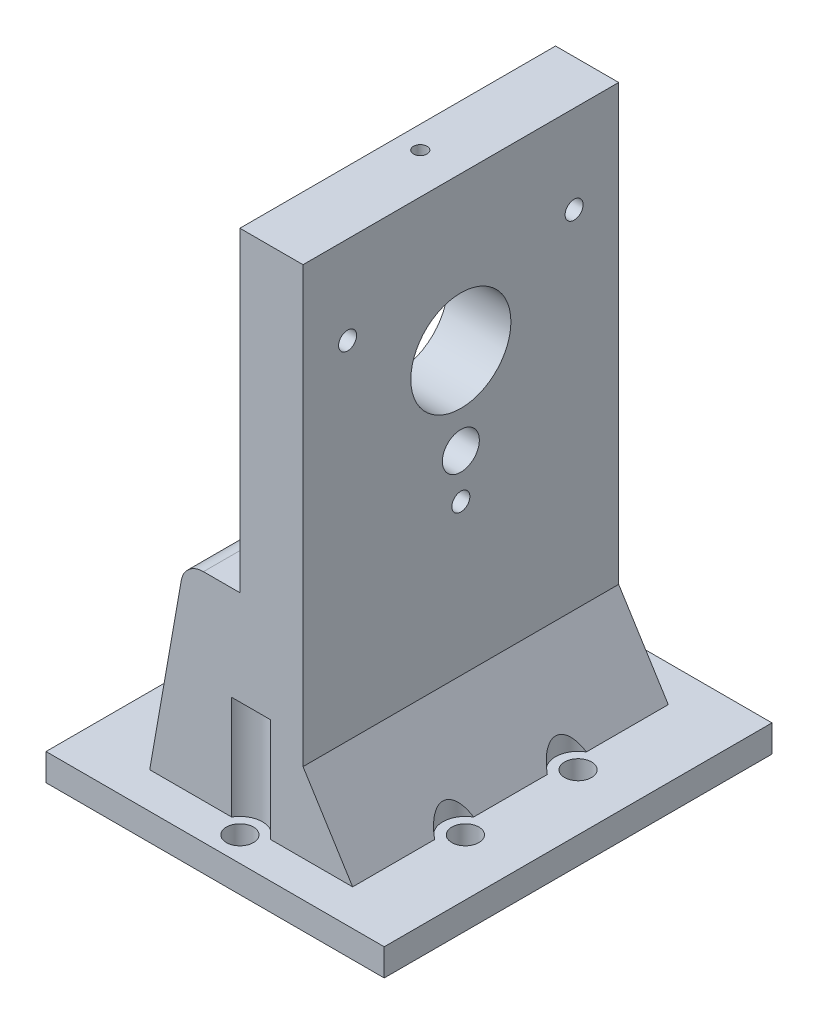
from build123d import *

# Parameters (mm, degrees)
SKETCH_1_W               = 35
SKETCH_1_H               = 70
EXTRUDE_1_DEPTH          = 6
SKETCH_1_W_2             = 26
EXTRUDE_1_2_DEPTH        = 6
SKETCH_1_3_W             = 14
SKETCH_1_3_H             = 70
EXTRUDE_2_DEPTH          = 120
EXTRUDE_4_DEPTH          = 70
EXTRUDE_7_DEPTH          = 70
SKETCH_7_R               = 3
CUT_EXTRUDE_4_DEPTH      = 121
SKETCH_8_R               = 5
CUT_EXTRUDE_5_DEPTH      = 115
SKETCH_3_R               = 11.1
SKETCH_3_R_2             = 4.1
SKETCH_3_R_3             = 2
CUT_EXTRUDE_8_DEPTH      = 36
CUT_EXTRUDE_8_DEPTH_BACK = 41
SKETCH_10_W              = 75
SKETCH_10_H              = 24
EXTRUDE_8_DEPTH          = 6
CUT_EXTRUDE_START        = -6
SKETCH_11_R              = 3
CUT_EXTRUDE_9_DEPTH      = 29
SKETCH_12_W              = 56.46589335
SKETCH_12_H              = 70
CUT_EXTRUDE_10_DEPTH     = 70
FILLET_1_R               = 5
SKETCH_13_R              = 5
CUT_EXTRUDE_11_DEPTH     = 23
SKETCH_14_W              = 75
SKETCH_14_H              = 16
CUT_EXTRUDE_12_DEPTH     = 10
SKETCH_15_R              = 1.5
CUT_EXTRUDE_13_DEPTH     = 6.25
SKETCH_16_R              = 1.5
CUT_EXTRUDE_14_DEPTH     = 6


with BuildPart() as part:
    # 草图1 → 凸台-拉伸1 (new body)
    with BuildSketch(Plane(origin=(0, 0, 0), x_dir=(1, 0, 0), z_dir=(0, 1, 0))):
        with Locations((17.5, -35)):
            Rectangle(SKETCH_1_W, SKETCH_1_H)
    extrude(amount=EXTRUDE_1_DEPTH)



with BuildPart() as body_2:
    # 草图1 → Extrude 1 2 (new body)
    with BuildSketch(Plane(origin=(0, 0, 0), x_dir=(1, 0, 0), z_dir=(0, 1, 0))):
        with Locations((62, -35)):
            Rectangle(SKETCH_1_W_2, SKETCH_1_H)
    extrude(amount=EXTRUDE_1_2_DEPTH)


with BuildPart() as part_1:
    add(part.part)

    add(body_2.part)  # 凸台-拉伸2 merges body 2
    # 草图1<3> → 凸台-拉伸2 (add)
    with BuildSketch(Plane(origin=(0, 0, 0), x_dir=(1, 0, 0), z_dir=(0, 1, 0))):
        with Locations((42, -35)):
            Rectangle(SKETCH_1_3_W, SKETCH_1_3_H)
    extrude(amount=EXTRUDE_2_DEPTH)

    # 草图4 → 凸台-拉伸4 (add, through all)
    with BuildSketch(Plane(origin=(0, 0, 0), x_dir=(-1, 0, 0), z_dir=(0, 0, -1))):
        Polygon((-35, 6), (-15, 6), (-35, 38), align=None)
        Polygon((-60, 6), (-40, 38), (-40, 6), align=None)
    extrude(amount=-EXTRUDE_4_DEPTH)

    # 草图9 → 凸台-拉伸7 (add, through all)
    with BuildSketch(Plane(origin=(0, 0, 0), x_dir=(-1, 0, 0), z_dir=(0, 0, -1))):
        Polygon((-35, 120), (-15, 6), (-35, 0), align=None)
    extrude(amount=-EXTRUDE_7_DEPTH)

    # 草图7 → 切除-拉伸4 (cut, through all)
    with BuildSketch(Plane.XZ):
        with Locations((62.5, 47.5)):
            Circle(SKETCH_7_R)
        with Locations((62.5, 22.5)):
            Circle(SKETCH_7_R)
        with Locations((12.5, 22.5)):
            Circle(SKETCH_7_R)
        with Locations((12.5, 47.5)):
            Circle(SKETCH_7_R)
    extrude(amount=-CUT_EXTRUDE_4_DEPTH, mode=Mode.SUBTRACT)

    # 草图8 → 切除-拉伸5 (cut)
    with BuildSketch(Plane(origin=(0, 6, 0), x_dir=(1, 0, 0), z_dir=(0, 1, 0))):
        with Locations((12.5, -47.5)):
            Circle(SKETCH_8_R)
        with Locations((12.5, -22.5)):
            Circle(SKETCH_8_R)
        with Locations((62.5, -47.5)):
            Circle(SKETCH_8_R)
        with Locations((62.5, -22.5)):
            Circle(SKETCH_8_R)
    extrude(amount=CUT_EXTRUDE_5_DEPTH, mode=Mode.SUBTRACT)

    # 草图3 → 切除-拉伸8 (cut, two sides)
    with BuildSketch(Plane.ZY.offset(-35)) as cut_extrude_8_sk:
        with Locations((35, 86)):
            Circle(SKETCH_3_R)
        with Locations((35, 66.75)):
            Circle(SKETCH_3_R_2)
        with Locations((35, 57)):
            Circle(SKETCH_3_R_3)
        with Locations((9.88526329, 100.5)):
            Circle(SKETCH_3_R_3)
        with Locations((60.11473671, 100.5)):
            Circle(SKETCH_3_R_3)
    extrude(amount=CUT_EXTRUDE_8_DEPTH, mode=Mode.SUBTRACT)
    extrude(cut_extrude_8_sk.sketch, amount=-CUT_EXTRUDE_8_DEPTH_BACK, mode=Mode.SUBTRACT)

    # 草图10 → 凸台-拉伸8 (add)
    with BuildSketch(Plane.XZ):
        with Locations((37.5, 82)):
            Rectangle(SKETCH_10_W, SKETCH_10_H)
    extrude_8 = extrude(amount=-EXTRUDE_8_DEPTH)

    # 草图11 → 切除-拉伸9 (cut)
    with BuildSketch(Plane(origin=(0, 6, 0), x_dir=(1, 0, 0), z_dir=(0, 1, 0)).offset(CUT_EXTRUDE_START)):
        with Locations((37.5, -72.5)):
            Circle(SKETCH_11_R)
    cut_extrude_9 = extrude(amount=CUT_EXTRUDE_9_DEPTH, mode=Mode.SUBTRACT)

    # 镜向1: 凸台-拉伸8, 切除-拉伸9 across plane
    add(extrude_8.mirror(Plane.XY.offset(35)))
    add(cut_extrude_9.mirror(Plane.XY.offset(35)), mode=Mode.SUBTRACT)

    # 草图12 → 切除-拉伸10 (cut)
    with BuildSketch(Plane(origin=(0, 120, 0), x_dir=(1, 0, 0), z_dir=(0, 1, 0))):
        with Locations((6.767053325, -35)):
            Rectangle(SKETCH_12_W, SKETCH_12_H)
    extrude(amount=-CUT_EXTRUDE_10_DEPTH, mode=Mode.SUBTRACT)

    # 圆角1
    fillet_1_edges = [part_1.edges().sort_by_distance(p)[0] for p in [
        (22.719298246, 50, 35),
    ]]
    fillet(fillet_1_edges, radius=FILLET_1_R)

    # 草图13 → 切除-拉伸11 (cut)
    with BuildSketch(Plane(origin=(0, 6, 0), x_dir=(1, 0, 0), z_dir=(0, 1, 0))):
        with Locations((37.5, -72.5)):
            Circle(SKETCH_13_R)
        with Locations((37.5, 2.5)):
            Circle(SKETCH_13_R)
    extrude(amount=CUT_EXTRUDE_11_DEPTH, mode=Mode.SUBTRACT)

    # 草图14 → 切除-拉伸12 (cut)
    with BuildSketch(Plane(origin=(0, 6, 0), x_dir=(1, 0, 0), z_dir=(0, 1, 0))):
        with Locations((37.5, 16)):
            Rectangle(SKETCH_14_W, SKETCH_14_H)
        with Locations((37.5, -86)):
            Rectangle(SKETCH_14_W, SKETCH_14_H)
    extrude(amount=-CUT_EXTRUDE_12_DEPTH, mode=Mode.SUBTRACT)

    # 草图15 → 切除-拉伸13 (cut)
    with BuildSketch(Plane(origin=(0, 120, 0), x_dir=(1, 0, 0), z_dir=(0, 1, 0))):
        with Locations((40, -35)):
            Circle(SKETCH_15_R)
    extrude(amount=-CUT_EXTRUDE_13_DEPTH, mode=Mode.SUBTRACT)

    # 草图16 → 切除-拉伸14 (cut)
    with BuildSketch(Plane.ZY.offset(-35)):
        with Locations((35, 115)):
            Circle(SKETCH_16_R)
    extrude(amount=-CUT_EXTRUDE_14_DEPTH, mode=Mode.SUBTRACT)


solid = part_1.part
